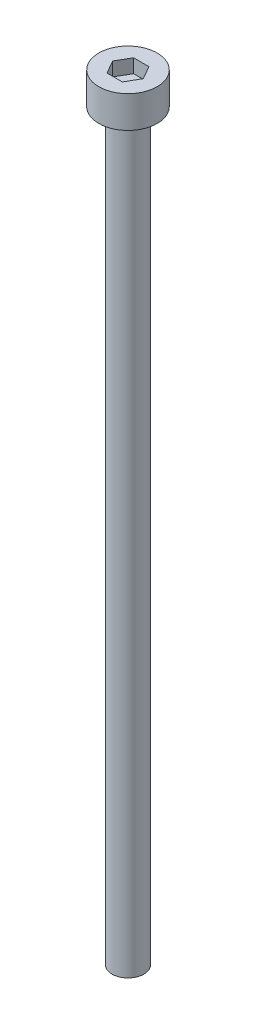
from build123d import *

# Parameters (mm, degrees)
SKETCH_1_R            = 2.75
EXTRUDE_248_DEPTH     = 3
CUT_EXTRUDE_378_DEPTH = 1.3
SKETCH_3_R            = 1.5
EXTRUDE_479_DEPTH     = 70


with BuildPart() as part:
    # 草图1 → Extrude 248 (new body)
    with BuildSketch(Plane(origin=(0, 0, 0), x_dir=(1, 0, 0), z_dir=(0, 1, 0))):
        Circle(SKETCH_1_R)
    extrude(amount=EXTRUDE_248_DEPTH)

    # 草图2 → Cut-Extrude 378 (cut)
    with BuildSketch(Plane(origin=(0, 3, 0), x_dir=(1, 0, 0), z_dir=(0, 1, 0))):
        Polygon((1.443375673, 0), (0.721687836, 1.25), (-0.721687836, 1.25), (-1.443375673, 0), (-0.721687836, -1.25), (0.721687836, -1.25), align=None)
    extrude(amount=-CUT_EXTRUDE_378_DEPTH, mode=Mode.SUBTRACT)

    # 草图3 → Extrude 479 (add)
    with BuildSketch(Plane.XZ):
        Circle(SKETCH_3_R)
    extrude(amount=EXTRUDE_479_DEPTH)


solid = part.part
